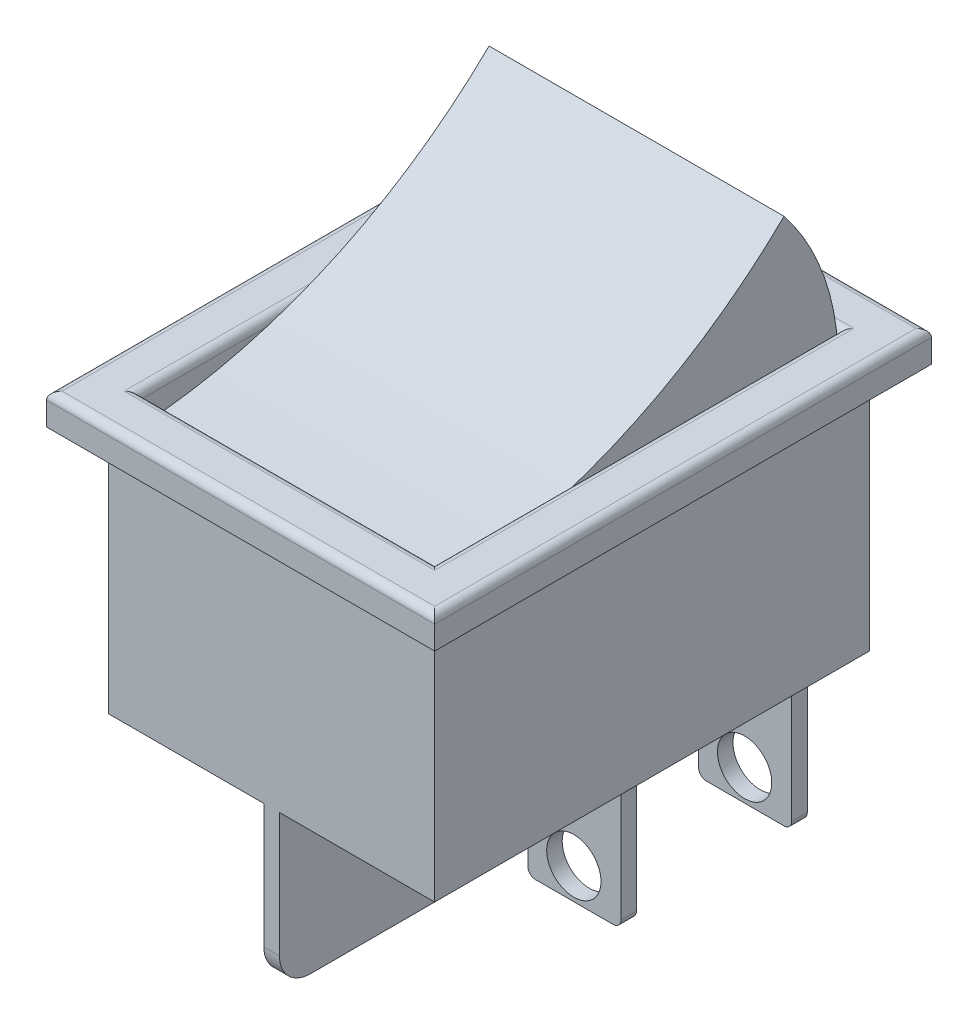
from build123d import *

# Parameters (mm, degrees)
SKETCH1_W             = 21
SKETCH1_H             = 28
BOSS_EXTRUDE1_DEPTH   = 16
SKETCH2_W             = 25
SKETCH2_H             = 32
SKETCH2_W_2           = 19
SKETCH2_H_2           = 26
BOSS_EXTRUDE2_DEPTH   = 2
FILLET1_R             = 0.5
SKETCH3_W             = 1
SKETCH3_H             = 28
BOSS_EXTRUDE3_DEPTH   = 10
SKETCH4_W             = 6
SKETCH4_H             = 1
BOSS_EXTRUDE4_DEPTH   = 9.5
BOSS_EXTRUDE4_2_DEPTH = 9.5
BOSS_EXTRUDE4_3_DEPTH = 9.5
BOSS_EXTRUDE4_4_DEPTH = 9.5
SKETCH5_R             = 1
SKETCH5_R_2           = 1.75
CUT_EXTRUDE1_DEPTH    = 29
FILLET2_R             = 2
FILLET3_R             = 0.5
FILLET4_R             = 0.5
FILLET5_R             = 0.5
FILLET6_R             = 0.5
BOSS_EXTRUDE5_DEPTH   = 9.5


with BuildPart() as part:
    # Sketch1 → Boss-Extrude1 (new body)
    with BuildSketch(Plane(origin=(0, 0, 0), x_dir=(1, 0, 0), z_dir=(0, 1, 0))):
        Rectangle(SKETCH1_W, SKETCH1_H)
    extrude(amount=BOSS_EXTRUDE1_DEPTH)

    # Sketch2 → Boss-Extrude2 (add)
    with BuildSketch(Plane(origin=(0, 16, 0), x_dir=(1, 0, 0), z_dir=(0, 1, 0))):
        Rectangle(SKETCH2_W, SKETCH2_H)
        Rectangle(SKETCH2_W_2, SKETCH2_H_2, mode=Mode.SUBTRACT)
    extrude(amount=BOSS_EXTRUDE2_DEPTH)

    # Fillet1
    fillet1_edges = [part.edges().sort_by_distance(p)[0] for p in [
        (0, 18, 16),
        (12.5, 18, 0),
        (0, 18, -16),
        (-12.5, 18, 0),
        (0, 18, 13),
        (9.5, 18, 0),
        (0, 18, -13),
        (-9.5, 18, 0),
    ]]
    fillet(fillet1_edges, radius=FILLET1_R)

    # Sketch3 → Boss-Extrude3 (add)
    with BuildSketch(Plane.XZ):
        Rectangle(SKETCH3_W, SKETCH3_H)
    extrude(amount=BOSS_EXTRUDE3_DEPTH)

    # Fillet2
    fillet2_edges = [part.edges().sort_by_distance(p)[0] for p in [
        (0, -10, 14),
        (0, -10, -14),
    ]]
    fillet(fillet2_edges, radius=FILLET2_R)


with BuildPart() as body_2:
    # Sketch4 → Boss-Extrude4 (new body)
    with BuildSketch(Plane.XZ):
        with Locations((-5.5, -11.5)):
            Rectangle(SKETCH4_W, SKETCH4_H)
    extrude(amount=BOSS_EXTRUDE4_DEPTH)


with BuildPart() as body_3:
    # Sketch4 → Boss-Extrude4 2 (new body)
    with BuildSketch(Plane.XZ):
        with Locations((5.5, -0.5)):
            Rectangle(SKETCH4_W, SKETCH4_H)
    extrude(amount=BOSS_EXTRUDE4_2_DEPTH)


with BuildPart() as body_4:
    # Sketch4 → Boss-Extrude4 3 (new body)
    with BuildSketch(Plane.XZ):
        with Locations((-5.5, -0.5)):
            Rectangle(SKETCH4_W, SKETCH4_H)
    extrude(amount=BOSS_EXTRUDE4_3_DEPTH)


with BuildPart() as body_5:
    # Sketch4 → Boss-Extrude4 4 (new body)
    with BuildSketch(Plane.XZ):
        with Locations((5.5, -11.5)):
            Rectangle(SKETCH4_W, SKETCH4_H)
    extrude(amount=BOSS_EXTRUDE4_4_DEPTH)


with BuildPart() as cut_extrude1_tool:
    # Sketch5 → Cut-Extrude1 (new body, through all)
    with BuildSketch(Plane(origin=(0, 0, -12), x_dir=(-1, 0, 0), z_dir=(0, 0, -1))):
        with Locations((5.460485821, -1.5)):
            Circle(SKETCH5_R)
        with Locations((5.460485821, -7.5)):
            Circle(SKETCH5_R_2)
        with Locations((-5.463804128, -1.721530738)):
            Circle(SKETCH5_R)
        with Locations((-5.463804128, -7.5)):
            Circle(SKETCH5_R_2)
    extrude(amount=-CUT_EXTRUDE1_DEPTH)


with BuildPart() as body_2_1:
    add(body_2.part)

    # Cut-Extrude1: cut by cut_extrude1_tool
    add(cut_extrude1_tool.part, mode=Mode.SUBTRACT)

    # Fillet4
    fillet4_edges = [body_2_1.edges().sort_by_distance(p)[0] for p in [
        (-8.5, -9.5, -11.5),
        (-2.5, -9.5, -11.5),
    ]]
    fillet(fillet4_edges, radius=FILLET4_R)


with BuildPart() as body_3_1:
    add(body_3.part)

    # Cut-Extrude1: cut by cut_extrude1_tool
    add(cut_extrude1_tool.part, mode=Mode.SUBTRACT)

    # Fillet5
    fillet5_edges = [body_3_1.edges().sort_by_distance(p)[0] for p in [
        (2.5, -9.5, -0.5),
        (8.5, -9.5, -0.5),
    ]]
    fillet(fillet5_edges, radius=FILLET5_R)


with BuildPart() as body_4_1:
    add(body_4.part)

    # Cut-Extrude1: cut by cut_extrude1_tool
    add(cut_extrude1_tool.part, mode=Mode.SUBTRACT)

    # Fillet6
    fillet6_edges = [body_4_1.edges().sort_by_distance(p)[0] for p in [
        (-2.5, -9.5, -0.5),
        (-8.5, -9.5, -0.5),
    ]]
    fillet(fillet6_edges, radius=FILLET6_R)


with BuildPart() as body_5_1:
    add(body_5.part)

    # Cut-Extrude1: cut by cut_extrude1_tool
    add(cut_extrude1_tool.part, mode=Mode.SUBTRACT)

    # Fillet3
    fillet3_edges = [body_5_1.edges().sort_by_distance(p)[0] for p in [
        (8.5, -9.5, -11.5),
        (2.5, -9.5, -11.5),
    ]]
    fillet(fillet3_edges, radius=FILLET3_R)


with BuildPart() as body_6:
    # Sketch6 → Boss-Extrude5 (new body, symmetric)
    with BuildSketch(Plane(origin=(0, 0, 0), x_dir=(0, 0, -1), z_dir=(1, 0, 0))):
        with BuildLine():
            Line((-13, 16), (13, 16))
            ThreePointArc((13, 16), (12.100922241, 21.296677467), (9.504407239, 26))
            ThreePointArc((9.504407239, 26), (-0.851466502, 18.98286274), (-13, 16))
        make_face()
    extrude(amount=BOSS_EXTRUDE5_DEPTH, both=True)


solid = Compound([part.part, body_2_1.part, body_3_1.part, body_4_1.part, body_5_1.part, body_6.part])
